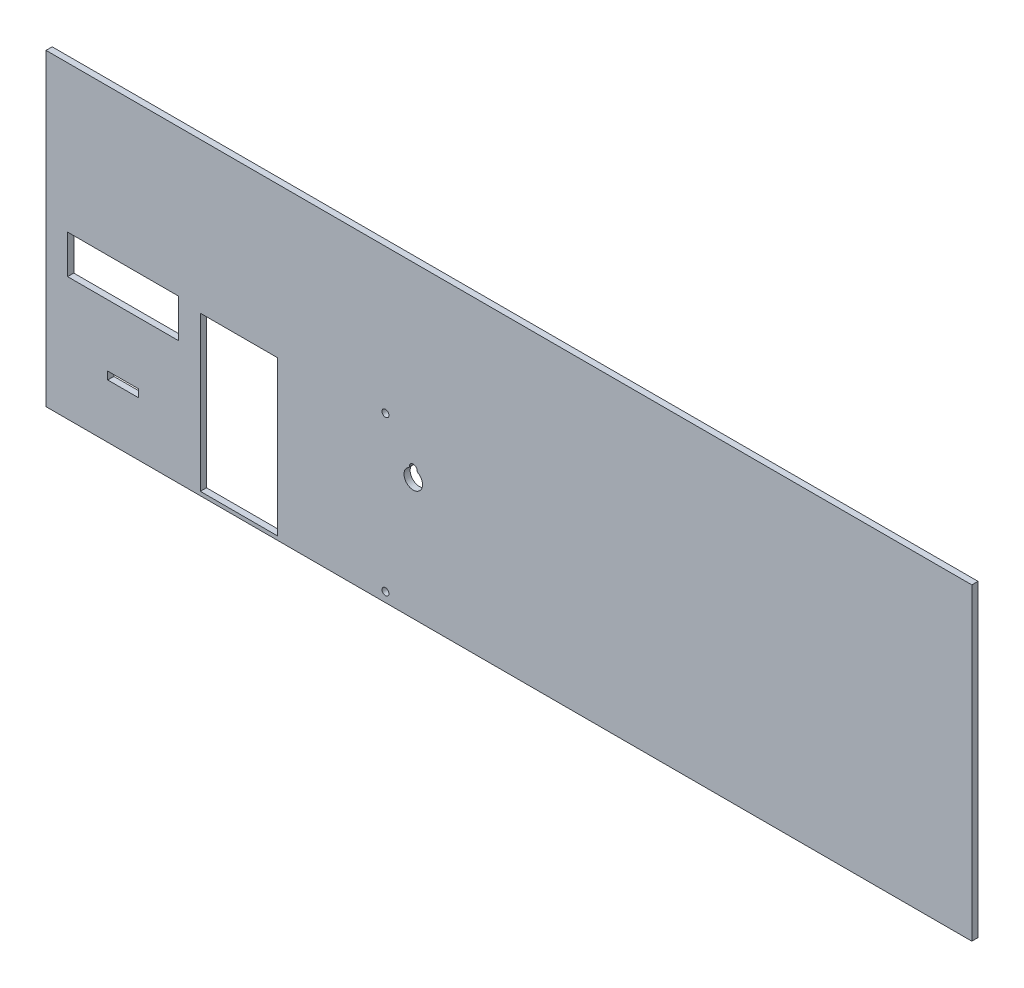
from build123d import *

# Parameters (mm, degrees)
SKETCH1_W           = 600
SKETCH1_H           = 200
SKETCH1_R           = 2.25
SKETCH1_W_2         = 50
SKETCH1_H_2         = 100
SKETCH1_W_3         = 20
SKETCH1_H_3         = 5
SKETCH1_W_4         = 72
SKETCH1_H_4         = 25
BOSS_EXTRUDE1_DEPTH = 4


with BuildPart() as part:
    # Sketch1 → Boss-Extrude1 (new body)
    with BuildSketch(Plane.XY):
        with Locations((300, 100)):
            Rectangle(SKETCH1_W, SKETCH1_H)
        with Locations((220, 106.30966113)):
            Circle(SKETCH1_R, mode=Mode.SUBTRACT)
        with Locations((220, 6.19033887)):
            Circle(SKETCH1_R, mode=Mode.SUBTRACT)
        with Locations((125, 52.5)):
            Rectangle(SKETCH1_W_2, SKETCH1_H_2, mode=Mode.SUBTRACT)
        with Locations((50, 37.5)):
            Rectangle(SKETCH1_W_3, SKETCH1_H_3, mode=Mode.SUBTRACT)
        with Locations((50, 92.5)):
            Rectangle(SKETCH1_W_4, SKETCH1_H_4, mode=Mode.SUBTRACT)
        with BuildLine():
            ThreePointArc((234.957275327, 83.37125), (238, 72.2), (241.042724673, 83.37125))
            ThreePointArc((241.042724673, 83.37125), (240.684092439, 83.732653501), (240.549888987, 84.223794014))
            ThreePointArc((240.549888987, 84.223794014), (238, 86.75), (235.450111013, 84.223794014))
            ThreePointArc((235.450111013, 84.223794014), (235.315907561, 83.732653501), (234.957275327, 83.37125))
        make_face(mode=Mode.SUBTRACT)
    extrude(amount=BOSS_EXTRUDE1_DEPTH)


solid = part.part
